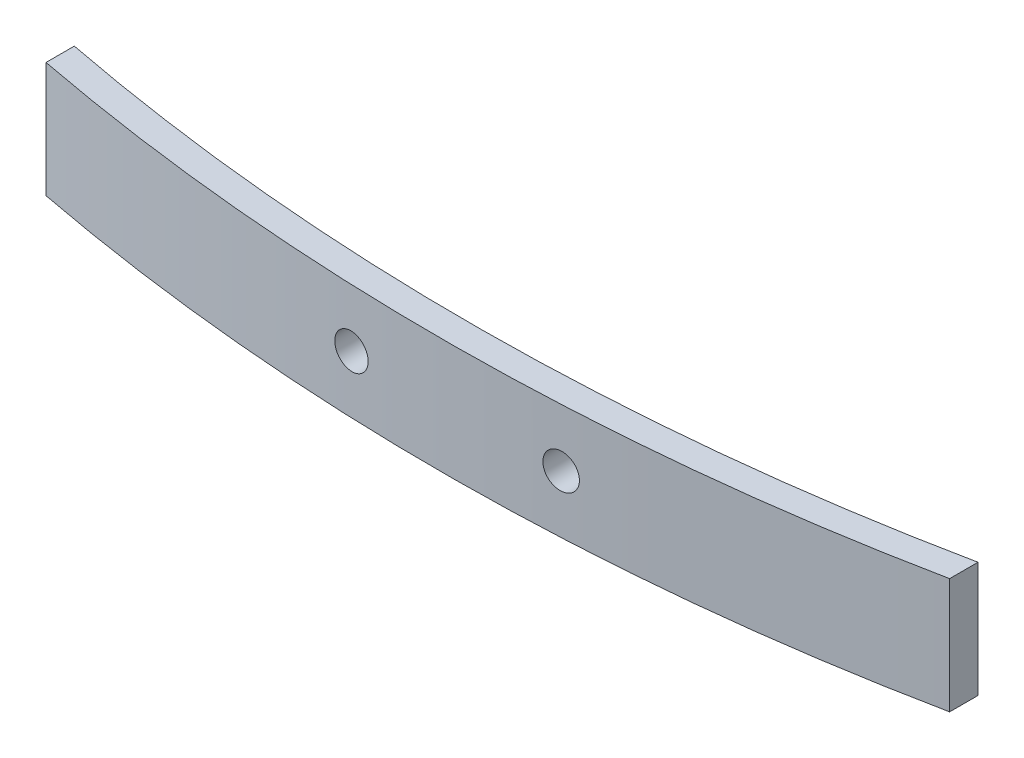
from build123d import *

# Parameters (mm, degrees)
BOSS_EXTRUDE1_DEPTH     = 8.3
SKETCH2_R               = 1.25
CUT_EXTRUDE1_DEPTH      = 3.700074126
CUT_EXTRUDE1_DEPTH_BACK = 3.668935167


with BuildPart() as part:
    # Sketch1 → Boss-Extrude1 (new body)
    with BuildSketch(Plane(origin=(0, 0, 0), x_dir=(1, 0, 0), z_dir=(0, 1, 0))):
        with BuildLine():
            Line((-32.309217612, 2.319893124), (-32.309217612, 0.283111159))
            ThreePointArc((-32.309217612, 0.283111159), (0.026735772, -2.697696531), (32.32905872, 0.627815151))
            Line((32.32905872, 0.627815151), (32.32905872, 2.668935167))
            ThreePointArc((32.32905872, 2.668935167), (0.027157554, -0.697665471), (-32.309217612, 2.319893124))
        make_face()
    extrude(amount=BOSS_EXTRUDE1_DEPTH)

    # Sketch2 → Cut-Extrude1 (cut, two sides)
    with BuildSketch(Plane.XY) as cut_extrude1_sk:
        with Locations((7.504960277, 4.15)):
            Circle(SKETCH2_R)
        with Locations((-7.495039723, 4.15)):
            Circle(SKETCH2_R)
    extrude(amount=CUT_EXTRUDE1_DEPTH, mode=Mode.SUBTRACT)
    extrude(cut_extrude1_sk.sketch, amount=-CUT_EXTRUDE1_DEPTH_BACK, mode=Mode.SUBTRACT)


solid = part.part
